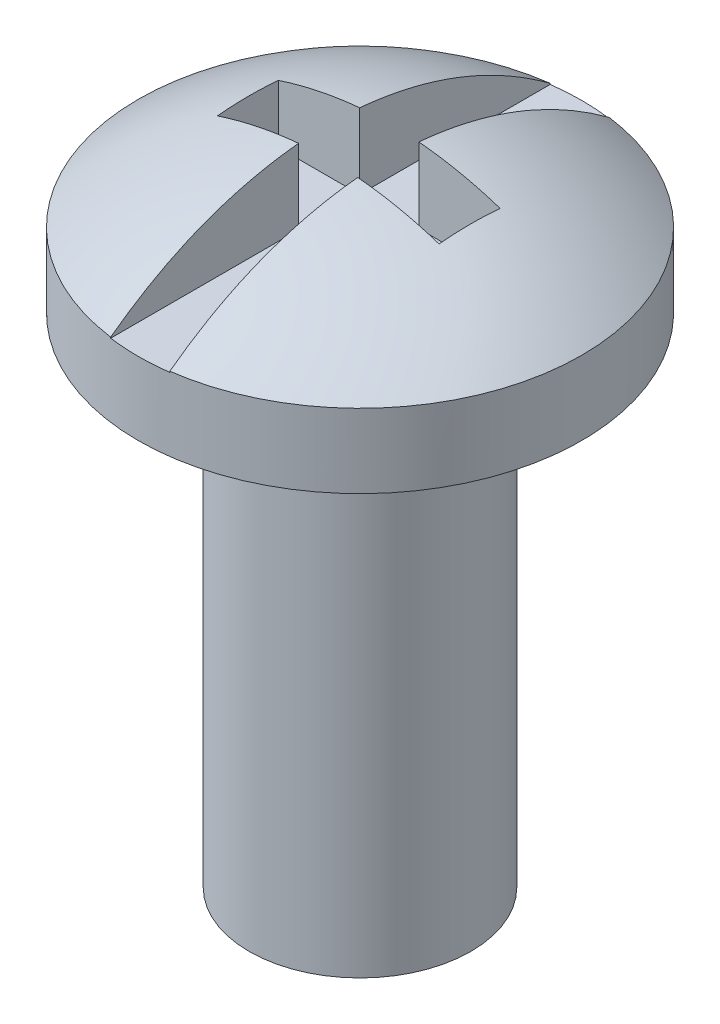
from build123d import *

# Parameters (mm, degrees)
SCHNITT_LINEAR_AUSTRAGEN1_DEPTH = 2.056247308


with BuildPart() as part:
    # Skizze1 → Rotation1 (revolve)
    with BuildSketch(Plane.XY):
        with BuildLine():
            Line((-3, -0.986868648), (-1.5, -0.986868648))
            Line((-1.5, -0.986868648), (-1.5, -7.722161257))
            Line((-1.5, -7.722161257), (0, -7.722161257))
            Line((0, -7.722161257), (0, 1.056247208))
            add(Edge.make_bspline(
                [(-3, 0.013131352), (-1.65504596, 1.020141519), (0, 1.056247208)],
                knots=[0, 0, 0, 0.690587557, 0.690587557, 0.690587557], degree=2))
            Line((-3, 0.013131352), (-3, -0.986868648))
        make_face()
    revolve(axis=Axis((0, 54.476945253, 0), (0, -1, 0)))

    # Skizze2 → Schnitt-Linear austragen1 (cut, through all)
    with BuildSketch(Plane(origin=(0, 0, 0), x_dir=(1, 0, 0), z_dir=(0, 1, 0))):
        Polygon((-0.4, 3.573663987), (0.4, 3.573663987), (0.4, 0.395605851), (1.5, 0.395605851), (1.5, -0.43040926), (0.4, -0.43040926), (0.4, -3.41246381), (-0.4, -3.41246381), (-0.4, -0.43040926), (-1.5, -0.43040926), (-1.5, 0.395605851), (-0.4, 0.395605851), align=None)
    extrude(amount=SCHNITT_LINEAR_AUSTRAGEN1_DEPTH, mode=Mode.SUBTRACT)


solid = part.part
